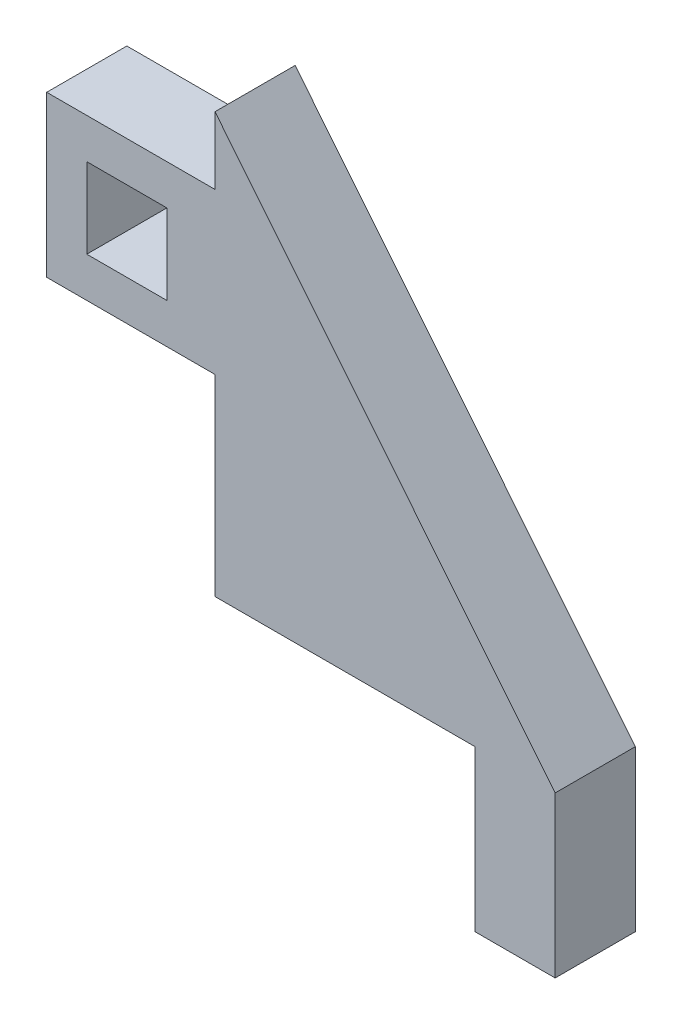
from build123d import *

# Parameters (mm, degrees)
BOSS_EXTRU_1_DEPTH      = 5
ESQUISSE3_W             = 5
ESQUISSE3_H             = 5
BOSS_EXTRU_3_DEPTH      = 10
ESQUISSE2_W             = 5
ESQUISSE2_H             = 10
BOSS_EXTRU_5_DEPTH      = 10.5
ESQUISSE4_W             = 5
ESQUISSE4_H             = 5
ENL_V_MAT_EXTRU_1_DEPTH = 10


with BuildPart() as part:
    # Esquisse1 → Boss.-Extru.1 (new body)
    with BuildSketch(Plane.XY):
        Polygon((0, 0), (0, 26.2), (21.226398658, 0), align=None)
    extrude(amount=BOSS_EXTRU_1_DEPTH)

    # Esquisse3 → Boss.-Extru.3 (add)
    with BuildSketch(Plane.XZ):
        with Locations((18.726398658, 2.5)):
            Rectangle(ESQUISSE3_W, ESQUISSE3_H)
    extrude(amount=BOSS_EXTRU_3_DEPTH)

    # Esquisse2 → Boss.-Extru.5 (add)
    with BuildSketch(Plane.ZY):
        with Locations((2.5, 17)):
            Rectangle(ESQUISSE2_W, ESQUISSE2_H)
    extrude(amount=BOSS_EXTRU_5_DEPTH)

    # Esquisse4 → Enlèv. mat.-Extru.1 (cut)
    with BuildSketch(Plane(origin=(0, 0, 0), x_dir=(-1, 0, 0), z_dir=(0, 0, -1))):
        with Locations((5.5, 17)):
            Rectangle(ESQUISSE4_W, ESQUISSE4_H)
    extrude(amount=-ENL_V_MAT_EXTRU_1_DEPTH, mode=Mode.SUBTRACT)


solid = part.part
